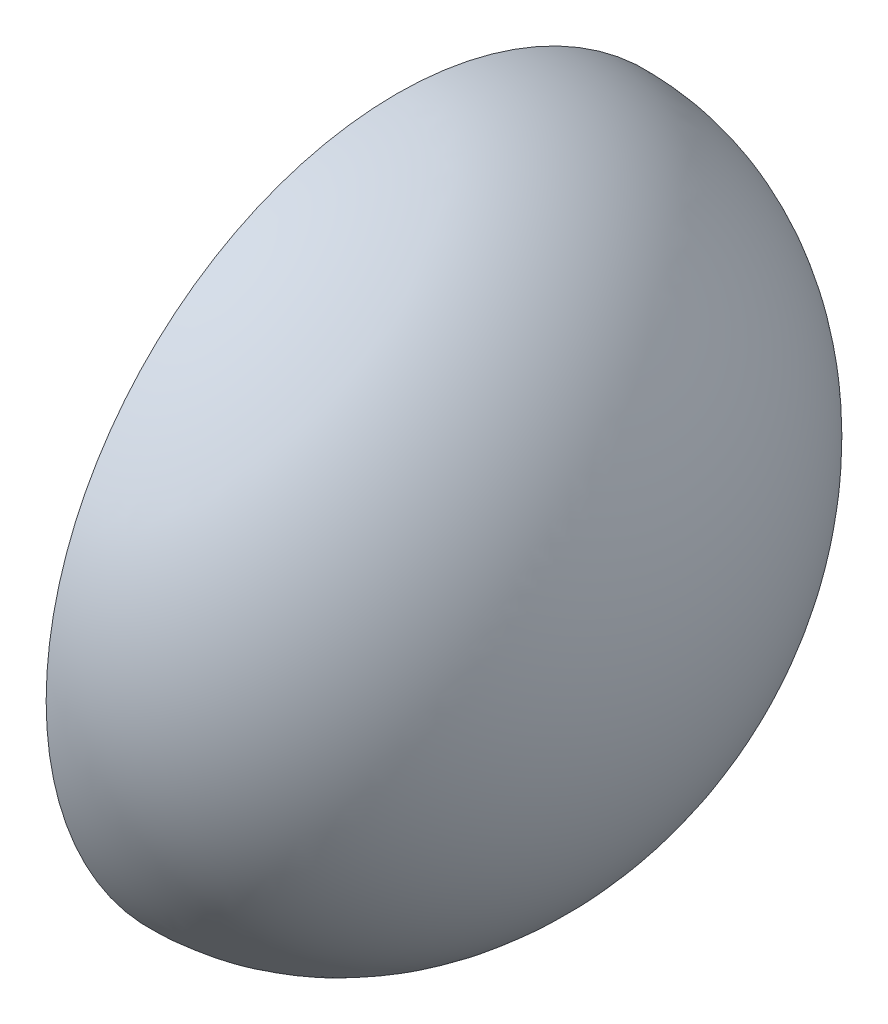
from build123d import *


with BuildPart() as part:
    # Sketch1 → Revolve1 (revolve)
    with BuildSketch(Plane.XY):
        with BuildLine():
            Line((10.7221, 0), (11.7221, 0))
            add(Edge.make_bspline(
                [(3.4163, -10.6172), (11.7221, -10.6172), (11.7221, 0)],
                knots=[0, 0, 0, 1.570796327, 1.570796327, 1.570796327], degree=2, weights=[1, 0.707106781, 1]))
            Line((3.4163, -10.6172), (3.4163, -9.6172))
            add(Edge.make_bspline(
                [(3.4163, -9.6172), (4.348793503, -9.6172), (6.173912679, -9.155830019), (8.629242175, -7.080308477), (10.319698012, -3.870965799), (10.7221, -1.266614453), (10.7221, 0)],
                knots=[0, 0, 0, 0, 0.392699082, 0.785398163, 1.178097245, 1.570796327, 1.570796327, 1.570796327, 1.570796327], degree=3))
        make_face()
    revolve(axis=Axis((-14.7193, 0, 0), (1, 0, 0)))


solid = part.part
